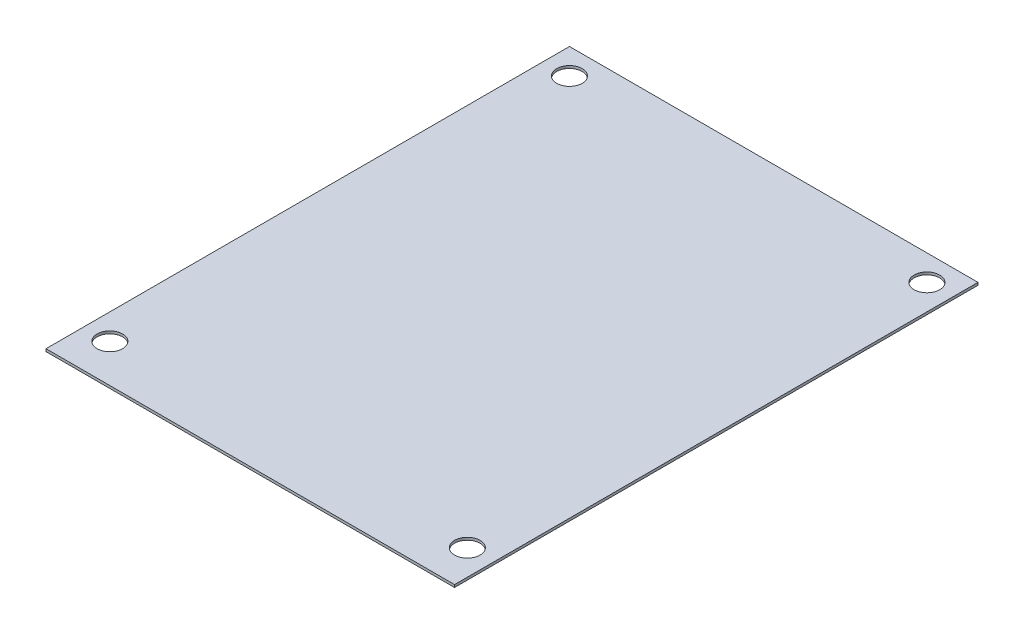
from build123d import *

# Parameters (mm, degrees)
SKETCH_1_W          = 320
SKETCH_1_H          = 410
EXTRUDE_1_DEPTH     = 2
SKETCH_2_R          = 10
CUT_EXTRUDE_1_DEPTH = 2


with BuildPart() as part:
    # 草图1 → 凸台-拉伸1 (new body)
    with BuildSketch(Plane(origin=(0, 0, 0), x_dir=(1, 0, 0), z_dir=(0, 1, 0))):
        with Locations((160, 205)):
            Rectangle(SKETCH_1_W, SKETCH_1_H)
    extrude(amount=EXTRUDE_1_DEPTH)

    # 草图2 → 切除-拉伸1 (cut)
    with BuildSketch(Plane(origin=(0, 2, 0), x_dir=(1, 0, 0), z_dir=(0, 1, 0))):
        with Locations((20, 390)):
            Circle(SKETCH_2_R)
        with Locations((300, 390)):
            Circle(SKETCH_2_R)
        with Locations((300, 30)):
            Circle(SKETCH_2_R)
        with Locations((20, 30)):
            Circle(SKETCH_2_R)
    extrude(amount=-CUT_EXTRUDE_1_DEPTH, mode=Mode.SUBTRACT)


solid = part.part
